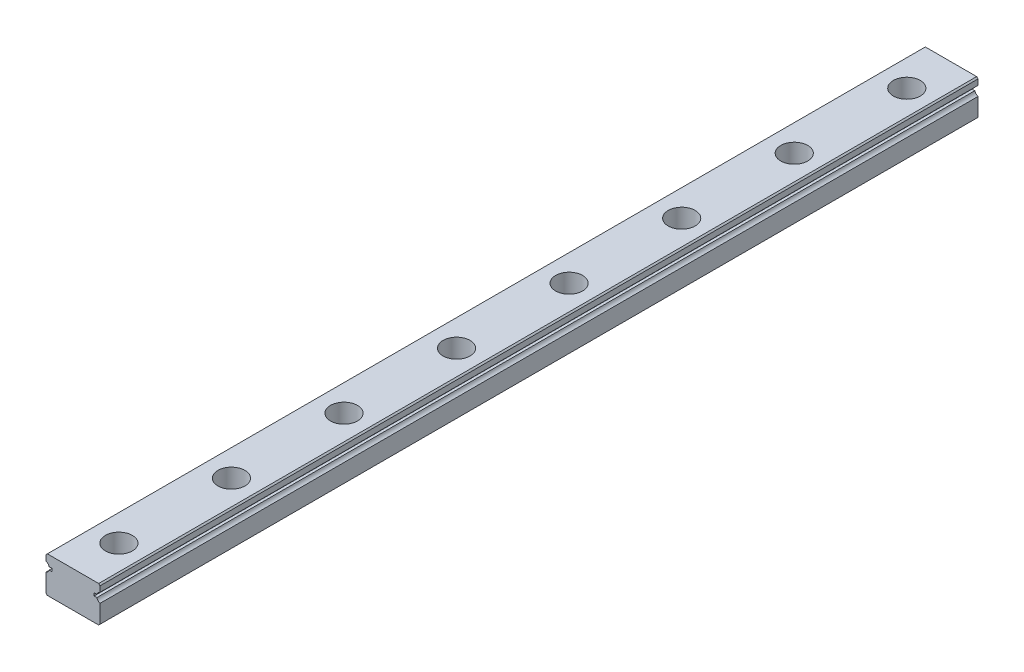
from build123d import *

# Parameters (mm, degrees)
EXTRUDE_1_DEPTH        = 195
SKETCH_2_R             = 3
SKETCH_2_R_2           = 1.75
CUT_EXTRUDE_1_DEPTH    = 4.5
SKETCH_2_2_R           = 1.75
CUT_EXTRUDE_2_DEPTH    = 196.256241898
PATTERN_LINEAR_1_COUNT = 12
PATTERN_LINEAR_1_PITCH = 25


with BuildPart() as part:
    # Эскиз1 → Бобышка-Вытянуть1 (new body)
    with BuildSketch(Plane.XY):
        with BuildLine():
            Line((-6, 3.7), (-5.7, 4))
            Line((-5.7, 4), (5.7, 4))
            Line((5.7, 4), (6, 3.7))
            Line((6, 3.7), (6, 2.449776022))
            ThreePointArc((6, 2.449776022), (5.561887715, 2.168810579), (5.297911886, 1.720256551))
            Line((5.297911886, 1.720256551), (4.687472904, 1.720256551))
            Line((4.687472904, 1.720256551), (4.687472904, 1.082255421))
            Line((4.687472904, 1.082255421), (5.292171789, 1.082255421))
            ThreePointArc((5.292171789, 1.082255421), (5.554928022, 0.621665058), (6, 0.333402583))
            Line((6, 0.333402583), (6, -3.7))
            Line((6, -3.7), (5.7, -4))
            Line((5.7, -4), (-5.7, -4))
            Line((-5.7, -4), (-6, -3.7))
            Line((-6, -3.7), (-6, 0.333402583))
            ThreePointArc((-6, 0.333402583), (-5.554928022, 0.621665058), (-5.292171789, 1.082255421))
            Line((-5.292171789, 1.082255421), (-4.687472904, 1.082255421))
            Line((-4.687472904, 1.082255421), (-4.687472904, 1.720256551))
            Line((-4.687472904, 1.720256551), (-5.297911886, 1.720256551))
            ThreePointArc((-5.297911886, 1.720256551), (-5.561887715, 2.168810579), (-6, 2.449776022))
            Line((-6, 2.449776022), (-6, 3.7))
        make_face()
    extrude(amount=EXTRUDE_1_DEPTH)

    # Эскиз2 → Вырез-Вытянуть1 (cut)
    with BuildSketch(Plane(origin=(0, 4, 0), x_dir=(1, 0, 0), z_dir=(0, 1, 0))):
        with Locations((0.188190244, -10)):
            Circle(SKETCH_2_R)
        with Locations((0.188190244, -10)):
            Circle(SKETCH_2_R_2, mode=Mode.SUBTRACT)
    cut_extrude_1 = extrude(amount=-CUT_EXTRUDE_1_DEPTH, mode=Mode.SUBTRACT)

    # Эскиз2<2> → Вырез-Вытянуть2 (cut, through all)
    with BuildSketch(Plane(origin=(0, 4, 0), x_dir=(1, 0, 0), z_dir=(0, 1, 0))):
        with Locations((0.188190244, -10)):
            Circle(SKETCH_2_2_R)
    cut_extrude_2 = extrude(amount=-CUT_EXTRUDE_2_DEPTH, mode=Mode.SUBTRACT)

    # Линейный массив1: Вырез-Вытянуть1, Вырез-Вытянуть2 ×12
    with Locations(*[(0, 0, i * PATTERN_LINEAR_1_PITCH) for i in range(1, PATTERN_LINEAR_1_COUNT)]):
        add(cut_extrude_1, mode=Mode.SUBTRACT)
        add(cut_extrude_2, mode=Mode.SUBTRACT)


solid = part.part
